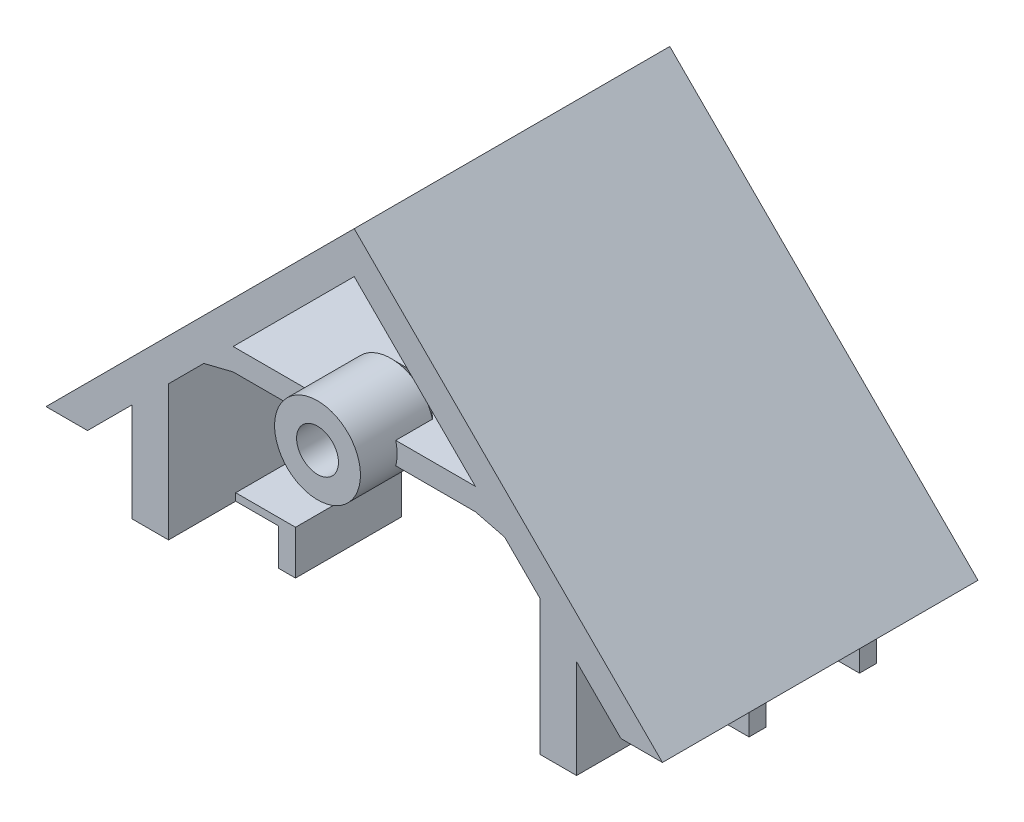
from build123d import *

# Parameters (mm, degrees)
BOSS_EXTRUDE1_DEPTH  = 21.5
BOSS_EXTRUDE7_START  = 5
SKETCH11_R           = 5.85
BOSS_EXTRUDE7_DEPTH  = 10
SKETCH12_R           = 2.85
CUT_EXTRUDE3_DEPTH   = 9
BOSS_EXTRUDE8_START  = 0.1
SKETCH14_W           = 5
SKETCH14_H           = 43
BOSS_EXTRUDE8_DEPTH  = 18.432718
SKETCH17_W           = 9.4
SKETCH17_H           = 2.3
BOSS_EXTRUDE10_DEPTH = 5
SKETCH18_W           = 8.15
SKETCH18_H           = 14.45
BOSS_EXTRUDE11_DEPTH = 1


with BuildPart() as part:
    # Sketch1 → Boss-Extrude1 (new body, symmetric)
    with BuildSketch(Plane.XY):
        Polygon((0, 0), (-42, -42), (-36.343145751, -42), (-32.343145751, -38), (-20.5, -26.156854249), (-16.5, -25.156854249), (16.5, -25.156854249), (20.5, -26.156854249), (32.343145751, -38), (36.343145751, -42), (42, -42), align=None)
        Polygon((-16.5, -22.156854249), (0, -5.656854249), (16.5, -22.156854249), align=None, mode=Mode.SUBTRACT)
    extrude(amount=BOSS_EXTRUDE1_DEPTH, both=True)

    # Sketch11 → Boss-Extrude7 (add)
    with BuildSketch(Plane.XY.offset(21.5).offset(BOSS_EXTRUDE7_START)):
        with Locations((0, -23.656854249)):
            Circle(SKETCH11_R)
    extrude(amount=-BOSS_EXTRUDE7_DEPTH)

    # Sketch12 → Cut-Extrude3 (cut)
    with BuildSketch(Plane(origin=(0, 0, 26.5), x_dir=(-1, 0, 0), z_dir=(0, 0, -1))):
        with Locations((0, -23.656854249)):
            Circle(SKETCH12_R)
    extrude(amount=CUT_EXTRUDE3_DEPTH, mode=Mode.SUBTRACT)

    # Sketch14 → Boss-Extrude8 (add)
    with BuildSketch(Plane(origin=(0, -49.48957189, 0), x_dir=(1, 0, 0), z_dir=(0, 1, 0)).offset(BOSS_EXTRUDE8_START)):
        with Locations((-27.8, 0)):
            Rectangle(SKETCH14_W, SKETCH14_H)
    boss_extrude8 = extrude(amount=BOSS_EXTRUDE8_DEPTH)

    # Sketch17 → Boss-Extrude10 (add)
    with BuildSketch(Plane.XZ.offset(49.38957189)):
        Polygon((-17.15, 12.35), (-17.15, -2.1), (-32.5, -2.1), (-32.5, 0.2), (-19.45, 0.2), (-19.45, 12.35), align=None)
        with Locations((-27.8, -16)):
            Rectangle(SKETCH17_W, SKETCH17_H)
    boss_extrude10 = extrude(amount=BOSS_EXTRUDE10_DEPTH)

    # Sketch18 → Boss-Extrude11 (add)
    with BuildSketch(Plane(origin=(0, -49.38957189, 0), x_dir=(1, 0, 0), z_dir=(0, 1, 0))):
        with Locations((-21.225, -5.125)):
            Rectangle(SKETCH18_W, SKETCH18_H)
    boss_extrude11 = extrude(amount=BOSS_EXTRUDE11_DEPTH)

    # Mirror2: Boss-Extrude8, Boss-Extrude10, Boss-Extrude11 across plane
    add(boss_extrude8.mirror(Plane(origin=(0, 0, 0), x_dir=(0, 0, 1), z_dir=(1, 0, 0))))
    add(boss_extrude10.mirror(Plane(origin=(0, 0, 0), x_dir=(0, 0, 1), z_dir=(1, 0, 0))))
    add(boss_extrude11.mirror(Plane(origin=(0, 0, 0), x_dir=(0, 0, 1), z_dir=(1, 0, 0))))

    # Sketch15 → Revolve1 (revolve)
    with BuildSketch(Plane(origin=(0, 0, 0), x_dir=(0, 0, -1), z_dir=(1, 0, 0))):
        Polygon((-16.5, -17.806854249), (-10.65, -23.656854249), (-16.5, -23.656854249), align=None)
    revolve(axis=Axis((0, -23.656854249, 10.65), (0, 0, 1)))


solid = part.part
